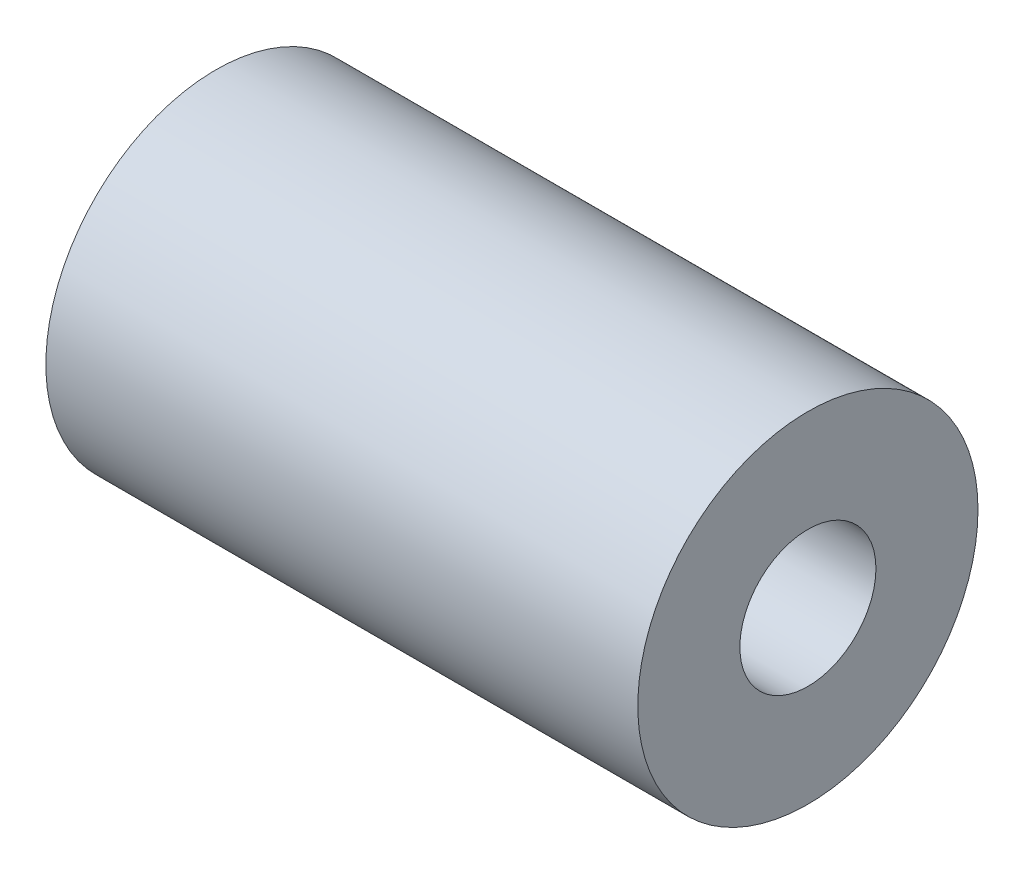
from build123d import *

# Parameters (mm, degrees)
ESBO_O1_W = 87
ESBO_O1_H = 15


with BuildPart() as part:
    # Esboço1 → Revolução1 (revolve)
    with BuildSketch(Plane.XY):
        with Locations((43.5, 17.5)):
            Rectangle(ESBO_O1_W, ESBO_O1_H)
    revolve(axis=Axis((0, 0, 0), (-1, 0, 0)))


solid = part.part
